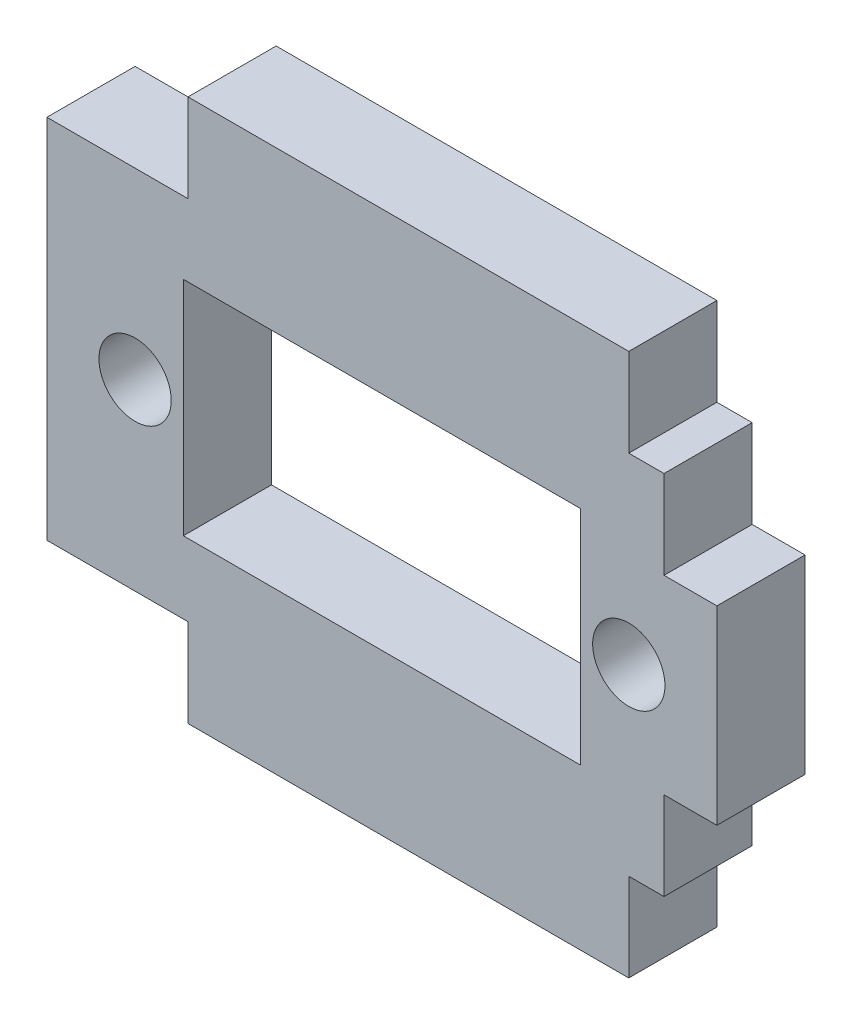
from build123d import *

# Parameters (mm, degrees)
SALIENTE_EXTRUIR1_DEPTH = 5
CUT_EXTRUDE1_REACH      = 7
CROQUIS2_R              = 2.05
CROQUIS2_W              = 22.53
CROQUIS2_H              = 12.6


with BuildPart() as part:
    # Croquis1 → Saliente-Extruir1 (new body)
    with BuildSketch(Plane.XY):
        Polygon((-12.5, 15.39), (12.5, 15.39), (12.5, 10.39), (14.5, 10.39), (14.5, 5.39), (17.5, 5.39), (17.5, -5.39), (14.5, -5.39), (14.5, -10.39), (12.5, -10.39), (12.5, -15.39), (-12.5, -15.39), (-12.5, -10.39), (-20.5, -10.39), (-20.5, 10.39), (-12.5, 10.39), align=None)
    extrude(amount=SALIENTE_EXTRUIR1_DEPTH)

    # Croquis2 → Cut-Extrude1 (cut, up to next)
    with BuildSketch(Plane.XY.offset(5), mode=Mode.PRIVATE) as cut_extrude1_sk1:
        with Locations((-15.5, 0)):
            Circle(CROQUIS2_R)
    cut_extrude1_tool1 = extrude(cut_extrude1_sk1.sketch, amount=-CUT_EXTRUDE1_REACH, mode=Mode.PRIVATE) & part.part
    add(cut_extrude1_tool1.solids().sort_by_distance((-15.5, 0, 5))[0], mode=Mode.SUBTRACT)
    # Croquis2 → Cut-Extrude1 (cut, up to next)
    with BuildSketch(Plane.XY.offset(5), mode=Mode.PRIVATE) as cut_extrude1_sk2:
        with Locations((12.5035, 0)):
            Circle(CROQUIS2_R)
    cut_extrude1_tool2 = extrude(cut_extrude1_sk2.sketch, amount=-CUT_EXTRUDE1_REACH, mode=Mode.PRIVATE) & part.part
    add(cut_extrude1_tool2.solids().sort_by_distance((12.5035, 0, 5))[0], mode=Mode.SUBTRACT)
    # Croquis2 → Cut-Extrude1 (cut, up to next)
    with BuildSketch(Plane.XY.offset(5), mode=Mode.PRIVATE) as cut_extrude1_sk3:
        with Locations((-1.49835, 0)):
            Rectangle(CROQUIS2_W, CROQUIS2_H)
    cut_extrude1_tool3 = extrude(cut_extrude1_sk3.sketch, amount=-CUT_EXTRUDE1_REACH, mode=Mode.PRIVATE) & part.part
    add(cut_extrude1_tool3.solids().sort_by_distance((-1.49835, 0, 5))[0], mode=Mode.SUBTRACT)


solid = part.part
